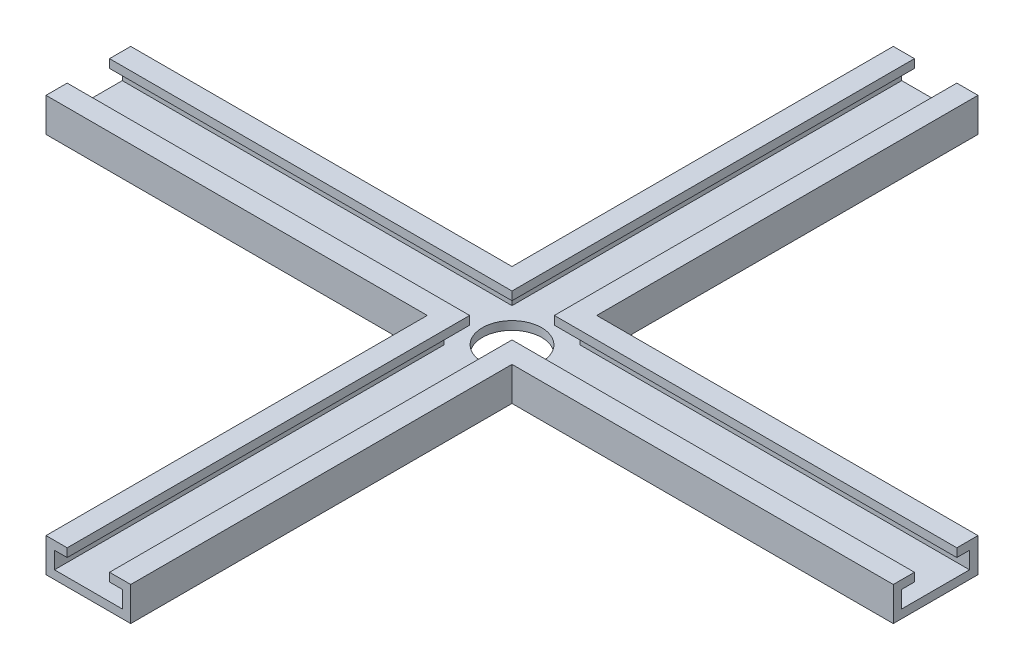
from build123d import *

# Parameters (mm, degrees)
EXTRUDE_1_DEPTH     = 200
EXTRUDE_2_DEPTH     = 100
CUT_EXTRUDE_1_DEPTH = 200
CUT_EXTRUDE_2_DEPTH = 200
CUT_EXTRUDE_3_DEPTH = 15


with BuildPart() as part:
    # 草图1 → 凸台-拉伸1 (new body)
    with BuildSketch(Plane.XY):
        Polygon((0, 0), (10, 0), (10, 8), (5, 8), (5, 6), (8, 6), (8, 2), (0, 2), (-8, 2), (-8, 6), (-5, 6), (-5, 8), (-10, 8), (-10, 0), align=None)
    extrude(amount=EXTRUDE_1_DEPTH)

    # 草图2 → 凸台-拉伸2 (add, symmetric)
    with BuildSketch(Plane(origin=(0, 0, 0), x_dir=(0, 0, -1), z_dir=(1, 0, 0))):
        Polygon((-100, 0), (-90, 0), (-90, 8), (-95, 8), (-95, 6), (-92, 6), (-92, 2), (-100, 2), (-108, 2), (-108, 6), (-105, 6), (-105, 8), (-110, 8), (-110, 0), align=None)
    extrude(amount=EXTRUDE_2_DEPTH, both=True)

    # 草图3 → 切除-拉伸1 (cut)
    with BuildSketch(Plane(origin=(100, 0, 0), x_dir=(0, 0, -1), z_dir=(1, 0, 0))):
        Polygon((-108, 6), (-105, 6), (-105, 8), (-95, 8), (-95, 6), (-92, 6), (-92, 2), (-108, 2), align=None)
    extrude(amount=-CUT_EXTRUDE_1_DEPTH, mode=Mode.SUBTRACT)

    # 草图4 → 切除-拉伸2 (cut)
    with BuildSketch(Plane.XY.offset(200)):
        Polygon((5, 6), (8, 6), (8, 2), (-8, 2), (-8, 6), (-5, 6), (-5, 8), (5, 8), align=None)
    extrude(amount=-CUT_EXTRUDE_2_DEPTH, mode=Mode.SUBTRACT)

    # 草图5 → 切除-拉伸3 (cut)
    with BuildSketch(Plane.XZ):
        with BuildLine():
            ThreePointArc((4.949747468, 104.949747468), (-4.949747468, 104.949747468), (-4.949747468, 95.050252532))
            Line((-4.949747468, 95.050252532), (4.949747468, 104.949747468))
        make_face()
        with BuildLine():
            Line((4.949747468, 104.949747468), (-4.949747468, 95.050252532))
            ThreePointArc((-4.949747468, 95.050252532), (2.678784027, 93.532843272), (7, 100))
            ThreePointArc((7, 100), (6.467156728, 102.678784027), (4.949747468, 104.949747468))
        make_face()
    extrude(amount=-CUT_EXTRUDE_3_DEPTH, mode=Mode.SUBTRACT)


solid = part.part
